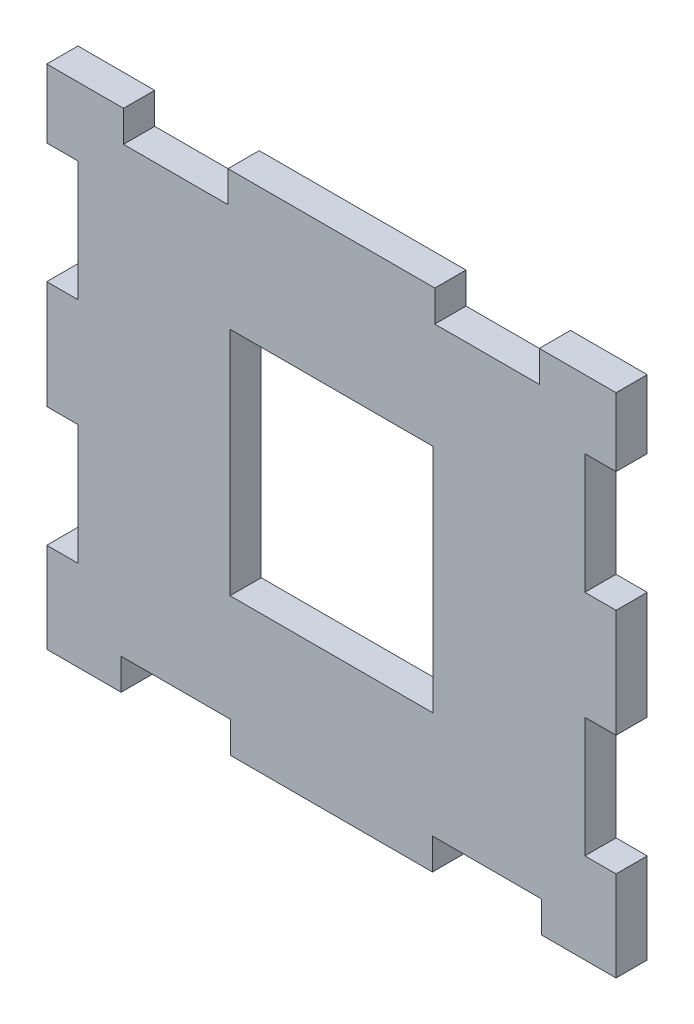
from build123d import *

# Parameters (mm, degrees)
ESBO_O1_W                = 13
ESBO_O1_H                = 14.8
ESBO_O1_W_2              = 13.26
ESBO_O1_H_2              = 2
ESBO_O1_W_3              = 2
ESBO_O1_H_3              = 6.93625866
ESBO_O1_W_4              = 12.96
RESSALTO_EXTRUS_O1_DEPTH = 2


with BuildPart() as part:
    # Esboço1 → Ressalto-extrusão1 (new body)
    with BuildSketch(Plane.XY):
        Polygon((-12.744415021, 9.596420323), (-15.664415021, 9.596420323), (-15.664415021, 7.212009238), (-15.664415021, -0.487990763), (-15.664415021, -7.424249423), (-15.664415021, -15.124249427), (-15.664415021, -18.903579677), (-12.894415021, -18.903579677), (-5.894415021, -18.903579677), (7.065584979, -18.903579677), (14.065584979, -18.903579677), (16.835584979, -18.903579677), (16.835584979, -15.124249427), (16.835584979, -7.424249423), (16.835584979, -0.487990763), (16.835584979, 7.212009238), (16.835584979, 9.596420323), (13.915584979, 9.596420323), (7.215584979, 9.596420323), (-6.044415021, 9.596420323), align=None)
        with Locations((0.585584979, -4.653579677)):
            Rectangle(ESBO_O1_W, ESBO_O1_H, mode=Mode.SUBTRACT)
        Polygon((13.915584979, 11.596420323), (13.915584979, 9.596420323), (16.835584979, 9.596420323), (16.835584979, 7.212009238), (18.835584979, 7.212009238), (18.835584979, 11.596420323), align=None)
        with Locations((0.585584979, 10.596420323)):
            Rectangle(ESBO_O1_W_2, ESBO_O1_H_2)
        Polygon((-15.664415021, 7.212009238), (-15.664415021, 9.596420323), (-12.744415021, 9.596420323), (-12.744415021, 11.596420323), (-17.664415021, 11.596420323), (-17.664415021, 7.212009238), align=None)
        with Locations((-16.664415021, -3.956120093)):
            Rectangle(ESBO_O1_W_3, ESBO_O1_H_3)
        Polygon((-15.664415021, -18.903579677), (-15.664415021, -15.124249427), (-17.664415021, -15.124249427), (-17.664415021, -20.903579677), (-12.894415021, -20.903579677), (-12.894415021, -18.903579677), align=None)
        with Locations((0.585584979, -19.903579677)):
            Rectangle(ESBO_O1_W_4, ESBO_O1_H_2)
        Polygon((18.835584979, -15.124249427), (16.835584979, -15.124249427), (16.835584979, -18.903579677), (14.065584979, -18.903579677), (14.065584979, -20.903579677), (18.835584979, -20.903579677), align=None)
        with Locations((17.835584979, -3.956120093)):
            Rectangle(ESBO_O1_W_3, ESBO_O1_H_3)
    extrude(amount=RESSALTO_EXTRUS_O1_DEPTH)


solid = part.part
